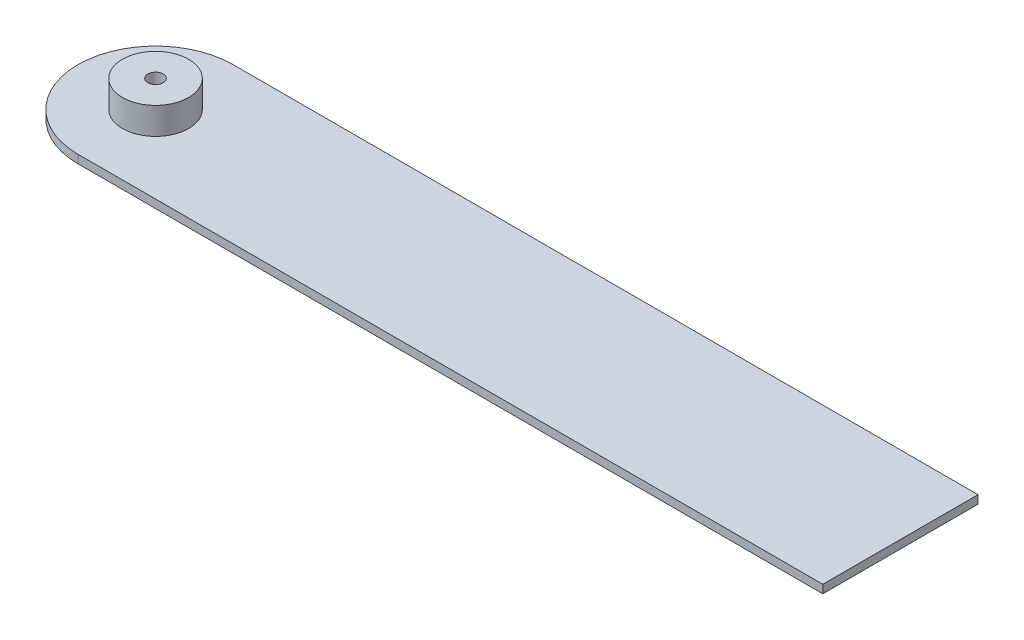
from build123d import *

# Parameters (mm, degrees)
BOSS_EXTRUDE1_DEPTH = 2
SKETCH2_R           = 0.74
CUT_EXTRUDE1_DEPTH  = 5.6
SKETCH6_W           = 79.5
SKETCH6_H           = 15
SKETCH6_R           = 3.2
CUT_EXTRUDE3_DEPTH  = 1.2
SKETCH7_R           = 3.2
SKETCH7_R_2         = 0.74
BOSS_EXTRUDE2_DEPTH = 1.4
SKETCH8_R           = 0.74
BOSS_EXTRUDE3_DEPTH = 0.4


with BuildPart() as part:
    # Sketch1 → Boss-Extrude1 (new body)
    with BuildSketch(Plane(origin=(0, 0, 0), x_dir=(1, 0, 0), z_dir=(0, 1, 0))):
        with BuildLine():
            ThreePointArc((7.5, 0), (5.303300859, -5.303300859), (0, -7.5))
            Line((0, -7.5), (72, -7.5))
            Line((72, -7.5), (72, 7.5))
            Line((72, 7.5), (0, 7.5))
            ThreePointArc((0, 7.5), (5.303300859, 5.303300859), (7.5, 0))
        make_face()
        with BuildLine():
            ThreePointArc((0, 7.5), (-7.5, 0), (0, -7.5))
            Line((0, -7.5), (0, 7.5))
        make_face()
        with BuildLine():
            Line((0, 7.5), (0, -7.5))
            ThreePointArc((0, -7.5), (5.303300859, -5.303300859), (7.5, 0))
            ThreePointArc((7.5, 0), (5.303300859, 5.303300859), (0, 7.5))
        make_face()
    extrude(amount=BOSS_EXTRUDE1_DEPTH)

    # Sketch2 → Cut-Extrude1 (cut)
    with BuildSketch(Plane(origin=(0, 2, 0), x_dir=(1, 0, 0), z_dir=(0, 1, 0))):
        Circle(SKETCH2_R)
    extrude(amount=-CUT_EXTRUDE1_DEPTH, mode=Mode.SUBTRACT)

    # Sketch6 → Cut-Extrude3 (cut)
    with BuildSketch(Plane(origin=(0, 2, 0), x_dir=(1, 0, 0), z_dir=(0, 1, 0))):
        with Locations((32.25, 0)):
            Rectangle(SKETCH6_W, SKETCH6_H)
        Circle(SKETCH6_R, mode=Mode.SUBTRACT)
    extrude(amount=-CUT_EXTRUDE3_DEPTH, mode=Mode.SUBTRACT)

    # Sketch7 → Boss-Extrude2 (add)
    with BuildSketch(Plane(origin=(0, 2, 0), x_dir=(1, 0, 0), z_dir=(0, 1, 0))):
        Circle(SKETCH7_R)
        Circle(SKETCH7_R_2, mode=Mode.SUBTRACT)
    extrude(amount=BOSS_EXTRUDE2_DEPTH)

    # Sketch8 → Boss-Extrude3 (add)
    with BuildSketch(Plane.XZ):
        Circle(SKETCH8_R)
    extrude(amount=-BOSS_EXTRUDE3_DEPTH)


solid = part.part
